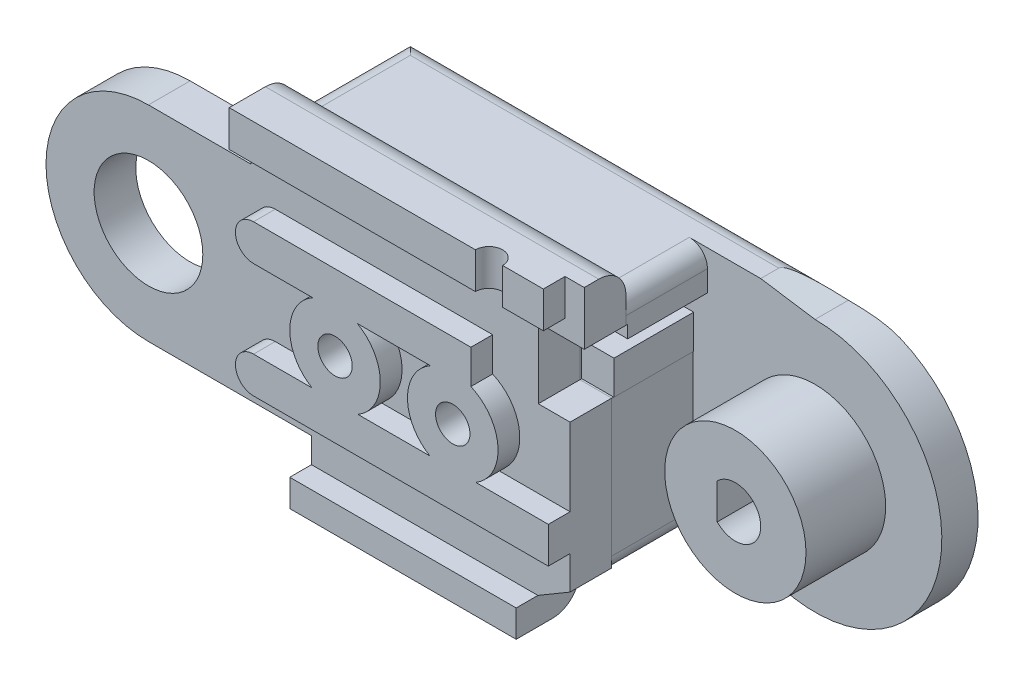
from build123d import *

# Parameters (mm, degrees)
BOSS_EXTRUDE1_DEPTH  = 2
BOSS_EXTRUDE6_DEPTH  = 4.5
CUT_EXTRUDE6_DEPTH   = 4.5
BOSS_EXTRUDE14_DEPTH = 2.3
SKETCH32_R           = 3
CUT_EXTRUDE7_DEPTH   = 2.3
SKETCH33_W           = 17.343145750507624
SKETCH33_H           = 2
BOSS_EXTRUDE15_DEPTH = 1.2
CUT_EXTRUDE8_DEPTH   = 2.4
CUT_EXTRUDE9_DEPTH   = 4.3999999999999995
SKETCH37_R           = 3.899999999999994
BOSS_EXTRUDE16_DEPTH = 4.4
CUT_EXTRUDE10_DEPTH  = 39.60291748102272
SKETCH43_R           = 2.5000000000000004
SKETCH43_R_2         = 2.4999999999999982
BOSS_EXTRUDE17_DEPTH = 1.2
SKETCH44_R           = 0.9499999999999992
SKETCH44_R_2         = 0.9500000000000008
CUT_EXTRUDE11_DEPTH  = 40.360198653546576
SKETCH45_R           = 1.9999999999999996
SKETCH45_R_2         = 2.000000000000003
CUT_EXTRUDE12_DEPTH  = 4.5
SKETCH49_R           = 0.7500000000000021
CUT_EXTRUDE13_DEPTH  = 3
CUT_EXTRUDE14_DEPTH  = 6.8
FILLET1_R            = 1.5
FILLET3_R            = 1


with BuildPart() as part:
    # Sketch3 → Boss-Extrude1 (new body)
    with BuildSketch(Plane.XY):
        with BuildLine():
            Line((8.000000000000002, 0), (8.999999999999993, -2.5431457505076343))
            Line((8.999999999999993, -2.5431457505076343), (8.999999999999993, -7.04314575050762))
            Line((8.999999999999993, -7.04314575050762), (21.50000000000003, -7.043145750507617))
            Line((21.50000000000003, -7.043145750507617), (25.05025253169419, -4.949747468305846))
            ThreePointArc((25.05025253169419, -4.949747468305846), (36.46715672757901, -2.678784026555599), (30, 7.000000000000014))
            Line((30, 7.000000000000014), (26.999999999999996, 7.456854249492377))
            Line((26.999999999999996, 7.456854249492377), (5.656854249492369, 7.456854249492377))
            Line((5.656854249492369, 7.456854249492377), (5.656854249492376, 5.656854249492382))
            ThreePointArc((5.656854249492376, 5.656854249492382), (7.391036260090296, 3.061467458920721), (8.000000000000002, 0))
        make_face()
    extrude(amount=BOSS_EXTRUDE1_DEPTH)

    # Sketch22 → Boss-Extrude6 (add)
    with BuildSketch(Plane.XY.offset(2)):
        with BuildLine():
            Line((5.656854249492376, 7.456854249492377), (21.50000000000004, 7.456854249492377))
            Line((21.50000000000004, 7.456854249492377), (26.999999999999996, 7.456854249492377))
            Line((26.999999999999996, 7.456854249492377), (26.999999999999996, 2.1288604946885763))
            Line((26.999999999999996, 2.1288604946885763), (23.27512626584711, 2.128860494688576))
            Line((23.27512626584711, 2.128860494688576), (23.27512626584711, -5.996446609406731))
            Line((23.27512626584711, -5.996446609406731), (21.50000000000003, -7.043145750507617))
            Line((21.50000000000003, -7.043145750507617), (8.999999999999993, -7.04314575050762))
            Line((8.999999999999993, -7.04314575050762), (8.999999999999993, -2.5431457505076343))
            Line((8.999999999999993, -2.5431457505076343), (7.999999999999998, 0))
            ThreePointArc((7.999999999999998, 0), (7.391036260090291, 3.061467458920719), (5.656854249492376, 5.656854249492382))
            Line((5.656854249492376, 5.656854249492382), (5.656854249492376, 7.456854249492377))
        make_face()
    extrude(amount=BOSS_EXTRUDE6_DEPTH)

    # Sketch26 → Cut-Extrude6 (cut)
    with BuildSketch(Plane.XY.offset(2)):
        Polygon((18.098080447707712, 5.299999999999999), (2.5300524575164793, 5.299999999999999), (2.5300524575164793, 4), (18.098080447707712, 4), (26.999999999999996, 4), (26.999999999999996, 5.299999999999999), align=None)
    extrude(amount=CUT_EXTRUDE6_DEPTH, mode=Mode.SUBTRACT)


with BuildPart() as body_2:
    # Sketch31 → Boss-Extrude14 (new body)
    with BuildSketch(Plane.XY.offset(6.5)):
        with BuildLine():
            Line((2.4326880657739025, 5.656854249492382), (0, 5.656854249492382))
            ThreePointArc((0, 5.656854249492382), (-5.656854249492382, 6.9e-16), (0, -5.656854249492382))
            Line((0, -5.656854249492382), (9.000000000000004, -5.656854249492382))
            Line((9.000000000000004, -5.656854249492382), (8.999999999999993, -7.04314575050762))
            Line((8.999999999999993, -7.04314575050762), (8.999999999999993, -8.54314575050762))
            Line((8.999999999999993, -8.54314575050762), (21.50000000000003, -8.54314575050762))
            Line((21.50000000000003, -8.54314575050762), (21.50000000000003, -7.043145750507617))
            Line((21.50000000000003, -7.043145750507617), (23.27512626584711, -5.996446609406731))
            Line((23.27512626584711, -5.996446609406731), (23.27512626584711, 2.128860494688576))
            Line((23.27512626584711, 2.128860494688576), (26.999999999999996, 2.1288604946885763))
            Line((26.999999999999996, 2.1288604946885763), (26.999999999999996, 7.456854249492377))
            Line((26.999999999999996, 7.456854249492377), (26.999999999999996, 8.956854249492377))
            Line((26.999999999999996, 8.956854249492377), (5.656854249492376, 8.956854249492377))
            Line((5.656854249492376, 8.956854249492377), (5.656854249492376, 7.456854249492377))
            Line((5.656854249492376, 7.456854249492377), (5.656854249492376, 5.656854249492382))
            Line((5.656854249492376, 5.656854249492382), (2.4326880657739025, 5.656854249492382))
        make_face()
    extrude(amount=BOSS_EXTRUDE14_DEPTH)

    # Sketch32 → Cut-Extrude7 (cut)
    with BuildSketch(Plane.XY.offset(8.799999999999999)):
        Circle(SKETCH32_R)
    extrude(amount=-CUT_EXTRUDE7_DEPTH, mode=Mode.SUBTRACT)

    # Sketch33 → Boss-Extrude15 (add)
    with BuildSketch(Plane.XY.offset(8.799999999999999)):
        with Locations((14.328427124746185, 7.956854249492377)):
            Rectangle(SKETCH33_W, SKETCH33_H)
        Polygon((9.000000000000004, -7.043145750507619), (9.000000000000004, -8.54314575050762), (21.50000000000003, -8.54314575050762), (21.50000000000003, -7.043145750507617), align=None)
        with BuildLine():
            Line((7.000000000000003, -4.156854249492383), (23.275126265847117, -4.156854249492383))
            Line((23.275126265847117, -4.156854249492383), (23.275126265847113, -2.1568542494923815))
            Line((23.275126265847113, -2.1568542494923815), (7.000000000000003, -2.1568542494923832))
            ThreePointArc((7.000000000000003, -2.1568542494923832), (6.000000000000003, -3.1568542494923832), (7.000000000000003, -4.156854249492383))
        make_face()
        with BuildLine():
            Line((18.999999999999996, 2.172006245196199), (7.000000000000003, 2.172006245196201))
            ThreePointArc((7.000000000000003, 2.172006245196201), (6.0000000000000036, 3.1720062451962), (7.000000000000003, 4.172006245196199))
            Line((7.000000000000003, 4.172006245196199), (18.999999999999996, 4.172006245196199))
            Line((18.999999999999996, 4.172006245196199), (18.999999999999996, 2.172006245196199))
        make_face()
    extrude(amount=BOSS_EXTRUDE15_DEPTH)


with BuildPart() as cut_extrude8_tool:
    # Sketch35 → Cut-Extrude8 (new body)
    with BuildSketch(Plane.XY.offset(8.799999999999999)):
        Polygon((26.999999999999996, 2.1288604946885763), (26.999999999999996, 6.000000000000002), (21.520354003499165, 6.000000000000002), (21.520354003499165, 2.1288604946885754), align=None)
    extrude(amount=-CUT_EXTRUDE8_DEPTH)


with BuildPart() as part_1:
    add(part.part)

    # Cut-Extrude8: cut by cut_extrude8_tool
    add(cut_extrude8_tool.part, mode=Mode.SUBTRACT)

    # Sketch36 → Cut-Extrude9 (cut)
    with BuildSketch(Plane.XY.offset(6.3999999999999995)):
        Polygon((26.999999999999996, 2.1288604946885763), (26.999999999999996, 4), (23.30000000000004, 3.999999999999999), (23.30000000000003, 2.1288604946885754), align=None)
    extrude(amount=-CUT_EXTRUDE9_DEPTH, mode=Mode.SUBTRACT)

    # Sketch37 → Boss-Extrude16 (add)
    with BuildSketch(Plane.XY.offset(2)):
        with Locations((29.999999999999996, 1.388e-14)):
            Circle(SKETCH37_R)
    extrude(amount=BOSS_EXTRUDE16_DEPTH)

    # Sketch39 → Cut-Extrude10 (cut, through all)
    with BuildSketch(Plane.XY.offset(6.4)):
        with BuildLine():
            Line((28.999999999999993, 0.9797958971132569), (28.999999999999993, -0.9797958971132569))
            ThreePointArc((28.999999999999993, -0.9797958971132569), (31.4, 2.383e-14), (28.999999999999993, 0.9797958971132569))
        make_face()
    extrude(amount=-CUT_EXTRUDE10_DEPTH, mode=Mode.SUBTRACT)


with BuildPart() as body_2_1:
    add(body_2.part)

    # Cut-Extrude8: cut by cut_extrude8_tool
    add(cut_extrude8_tool.part, mode=Mode.SUBTRACT)

    # Sketch43 → Boss-Extrude17 (add)
    with BuildSketch(Plane.XY.offset(8.799999999999999)):
        with Locations((11.500000000000004, 0)):
            Circle(SKETCH43_R)
        with Locations((18.000000000000004, 0)):
            Circle(SKETCH43_R_2)
    extrude(amount=BOSS_EXTRUDE17_DEPTH)


with BuildPart() as cut_extrude11_tool:
    # Sketch44 → Cut-Extrude11 (new, through all)
    with BuildSketch(Plane.XY.offset(9.999999999999998)):
        with Locations((11.500000000000004, 0)):
            Circle(SKETCH44_R)
        with Locations((18.000000000000004, 0)):
            Circle(SKETCH44_R_2)
    extrude(amount=-CUT_EXTRUDE11_DEPTH)


with BuildPart() as part_2:
    add(part_1.part)

    # Cut-Extrude11: cut by cut_extrude11_tool
    add(cut_extrude11_tool.part, mode=Mode.SUBTRACT)

    # Sketch45 → Cut-Extrude12 (cut)
    with BuildSketch(Plane(origin=(0, 0, 0), x_dir=(-1, 0, 0), z_dir=(0, 0, -1))):
        with Locations((-11.500000000000004, 0)):
            Circle(SKETCH45_R)
        with Locations((-18.000000000000004, 0)):
            Circle(SKETCH45_R_2)
    extrude(amount=-CUT_EXTRUDE12_DEPTH, mode=Mode.SUBTRACT)


with BuildPart() as body_2_2:
    add(body_2_1.part)

    # Cut-Extrude11: cut by cut_extrude11_tool
    add(cut_extrude11_tool.part, mode=Mode.SUBTRACT)

    # Sketch49 → Cut-Extrude13 (cut)
    with BuildSketch(Plane.XZ.offset(-6.956854249492377)):
        with Locations((19.999999999999996, 9.999999999999998)):
            Circle(SKETCH49_R)
    extrude(amount=-CUT_EXTRUDE13_DEPTH, mode=Mode.SUBTRACT)


with BuildPart() as cut_extrude14_tool:
    # Sketch51 → Cut-Extrude14 (new body)
    with BuildSketch(Plane.XY.offset(8.799999999999999)):
        Polygon((27, 8.956854249492377), (24.058650564533934, 8.956854249492377), (24.058650564533938, 4.991269007681976), (26.999999999999996, 4.991269007681976), align=None)
    extrude(amount=-CUT_EXTRUDE14_DEPTH)


with BuildPart() as part_3:
    add(part_2.part)

    # Cut-Extrude14: cut by cut_extrude14_tool
    add(cut_extrude14_tool.part, mode=Mode.SUBTRACT)

    # Fillet3
    fillet3_edges = [part_3.edges().sort_by_distance(p)[0] for p in [
        (23.27512626584711, -5.996446609406731, 4.25),
        (24.058650564533934, 7.456854249492377, 4.25),
        (8.999999999999993, -7.04314575050762, 3.25),
        (5.656854249492373, 7.456854249492377, 3.25),
        (15.25000000000001, -7.043145750507618, 0),
        (16.328427124746185, 7.456854249492377, 0),
    ]]
    fillet(fillet3_edges, radius=FILLET3_R)


with BuildPart() as body_2_3:
    add(body_2_2.part)

    # Cut-Extrude14: cut by cut_extrude14_tool
    add(cut_extrude14_tool.part, mode=Mode.SUBTRACT)

    # Fillet1
    fillet1_edges = [body_2_3.edges().sort_by_distance(p)[0] for p in [
        (14.857752407013155, 8.956854249492377, 6.5),
        (15.25000000000001, -8.54314575050762, 6.5),
    ]]
    fillet(fillet1_edges, radius=FILLET1_R)


solid = Compound([part_3.part, body_2_3.part])
